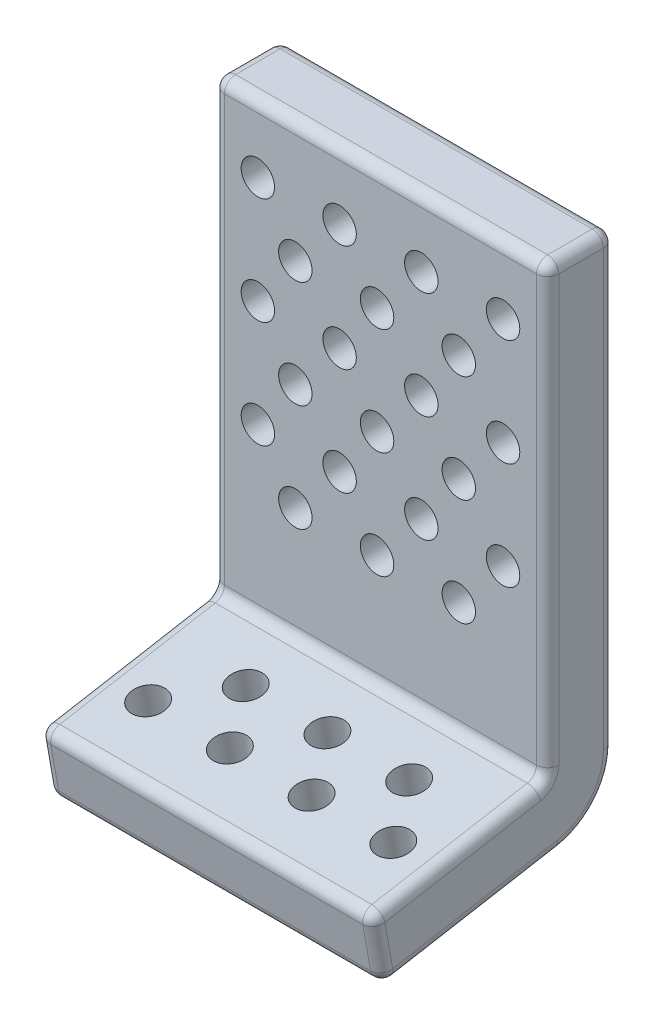
from build123d import *

# Parameters (mm, degrees)
EXTRUDE_1_DEPTH                = 15
SKETCH_2_R                     = 0.75
CUT_EXTRUDE_1_DEPTH            = 15
SKETCH_3_R                     = 0.75
CUT_EXTRUDE_2_DEPTH            = 15
CUT_EXTRUDE_START              = -2.7
SKETCH_2_2_R                   = 0.75
CUT_EXTRUDE_3_DEPTH            = 1
CUT_EXTRUDE_3_DRAFT            = 60
CUT_EXTRUDE_3_PROFILE_2_DEPTH  = 1
CUT_EXTRUDE_3_PROFILE_2_DRAFT  = 60
CUT_EXTRUDE_3_PROFILE_3_DEPTH  = 1
CUT_EXTRUDE_3_PROFILE_3_DRAFT  = 60
CUT_EXTRUDE_3_PROFILE_4_DEPTH  = 1
CUT_EXTRUDE_3_PROFILE_4_DRAFT  = 60
CUT_EXTRUDE_3_PROFILE_5_DEPTH  = 1
CUT_EXTRUDE_3_PROFILE_5_DRAFT  = 60
CUT_EXTRUDE_3_PROFILE_6_DEPTH  = 1
CUT_EXTRUDE_3_PROFILE_6_DRAFT  = 60
CUT_EXTRUDE_3_PROFILE_7_DEPTH  = 1
CUT_EXTRUDE_3_PROFILE_7_DRAFT  = 60
CUT_EXTRUDE_3_PROFILE_8_DEPTH  = 1
CUT_EXTRUDE_3_PROFILE_8_DRAFT  = 60
CUT_EXTRUDE_3_PROFILE_9_DEPTH  = 1
CUT_EXTRUDE_3_PROFILE_9_DRAFT  = 60
CUT_EXTRUDE_3_PROFILE_10_DEPTH = 1
CUT_EXTRUDE_3_PROFILE_10_DRAFT = 60
CUT_EXTRUDE_3_PROFILE_11_DEPTH = 1
CUT_EXTRUDE_3_PROFILE_11_DRAFT = 60
CUT_EXTRUDE_3_PROFILE_12_DEPTH = 1
CUT_EXTRUDE_3_PROFILE_12_DRAFT = 60
CUT_EXTRUDE_3_PROFILE_13_DEPTH = 1
CUT_EXTRUDE_3_PROFILE_13_DRAFT = 60
CUT_EXTRUDE_3_PROFILE_14_DEPTH = 1
CUT_EXTRUDE_3_PROFILE_14_DRAFT = 60
CUT_EXTRUDE_3_PROFILE_15_DEPTH = 1
CUT_EXTRUDE_3_PROFILE_15_DRAFT = 60
CUT_EXTRUDE_3_PROFILE_16_DEPTH = 1
CUT_EXTRUDE_3_PROFILE_16_DRAFT = 60
CUT_EXTRUDE_3_PROFILE_17_DEPTH = 1
CUT_EXTRUDE_3_PROFILE_17_DRAFT = 60
CUT_EXTRUDE_3_PROFILE_18_DEPTH = 1
CUT_EXTRUDE_3_PROFILE_18_DRAFT = 60
CUT_EXTRUDE_3_PROFILE_19_DEPTH = 1
CUT_EXTRUDE_3_PROFILE_19_DRAFT = 60
CUT_EXTRUDE_3_PROFILE_20_DEPTH = 1
CUT_EXTRUDE_3_PROFILE_20_DRAFT = 60
CUT_EXTRUDE_3_PROFILE_21_DEPTH = 1
CUT_EXTRUDE_3_PROFILE_21_DRAFT = 60
CUT_EXTRUDE_START_2            = 2.7
SKETCH_3_2_R                   = 0.75
CUT_EXTRUDE_4_DEPTH            = 1
CUT_EXTRUDE_4_DRAFT            = -60
CUT_EXTRUDE_4_PROFILE_2_DEPTH  = 1
CUT_EXTRUDE_4_PROFILE_2_DRAFT  = -60
CUT_EXTRUDE_4_PROFILE_3_DEPTH  = 1
CUT_EXTRUDE_4_PROFILE_3_DRAFT  = -60
CUT_EXTRUDE_4_PROFILE_4_DEPTH  = 1
CUT_EXTRUDE_4_PROFILE_4_DRAFT  = -60
CUT_EXTRUDE_4_PROFILE_5_DEPTH  = 1
CUT_EXTRUDE_4_PROFILE_5_DRAFT  = -60
CUT_EXTRUDE_4_PROFILE_6_DEPTH  = 1
CUT_EXTRUDE_4_PROFILE_6_DRAFT  = -60
CUT_EXTRUDE_4_PROFILE_7_DEPTH  = 1
CUT_EXTRUDE_4_PROFILE_7_DRAFT  = -60
FILLET_1_R                     = 0.5


with BuildPart() as part:
    # Эскиз1 → Бобышка-Вытянуть1 (new body)
    with BuildSketch(Plane(origin=(0, 0, 0), x_dir=(0, 0, -1), z_dir=(1, 0, 0))):
        with BuildLine():
            Line((0, 0), (-3, 0))
            Line((-3, 0), (-3, -20))
            Line((-3, -20), (-10.878462024, -21.389185421))
            Line((-10.878462024, -21.389185421), (-10.357517491, -24.34360868))
            Line((-10.357517491, -24.34360868), (-2.479055467, -22.954423259))
            ThreePointArc((-2.479055467, -22.954423259), (-0.701866671, -21.928362829), (0, -20))
            Line((0, -20), (0, 0))
        make_face()
    extrude(amount=EXTRUDE_1_DEPTH)

    # Эскиз2 → Вырез-Вытянуть1 (cut)
    with BuildSketch(Plane.XY.offset(3)):
        with Locations((2, -3)):
            Circle(SKETCH_2_R)
        with Locations((5.666666667, -3)):
            Circle(SKETCH_2_R)
        with Locations((9.333333333, -3)):
            Circle(SKETCH_2_R)
        with Locations((13, -3)):
            Circle(SKETCH_2_R)
        with Locations((3.680498092, -5.4)):
            Circle(SKETCH_2_R)
        with Locations((7.347164758, -5.4)):
            Circle(SKETCH_2_R)
        with Locations((11.013831425, -5.4)):
            Circle(SKETCH_2_R)
        with Locations((2, -7.8)):
            Circle(SKETCH_2_R)
        with Locations((5.666666667, -7.8)):
            Circle(SKETCH_2_R)
        with Locations((3.680498092, -10.2)):
            Circle(SKETCH_2_R)
        with Locations((7.347164758, -10.2)):
            Circle(SKETCH_2_R)
        with Locations((9.333333333, -7.8)):
            Circle(SKETCH_2_R)
        with Locations((11.013831425, -10.2)):
            Circle(SKETCH_2_R)
        with Locations((13, -7.8)):
            Circle(SKETCH_2_R)
        with Locations((2, -12.6)):
            Circle(SKETCH_2_R)
        with Locations((5.666666667, -12.6)):
            Circle(SKETCH_2_R)
        with Locations((3.680498092, -15)):
            Circle(SKETCH_2_R)
        with Locations((7.347164758, -15)):
            Circle(SKETCH_2_R)
        with Locations((9.333333333, -12.6)):
            Circle(SKETCH_2_R)
        with Locations((11.013831425, -15)):
            Circle(SKETCH_2_R)
        with Locations((13, -12.6)):
            Circle(SKETCH_2_R)
    extrude(amount=-CUT_EXTRUDE_1_DEPTH, mode=Mode.SUBTRACT)

    # Эскиз3 → Вырез-Вытянуть2 (cut)
    with BuildSketch(Plane(origin=(0, -23.26814693, 21.534582269), x_dir=(1, 0, 0), z_dir=(0, -0.9848077530122086, -0.1736481776669274))):
        with Locations((2, -13.820508076)):
            Circle(SKETCH_3_R)
        with Locations((5.666666667, -13.820508076)):
            Circle(SKETCH_3_R)
        with Locations((9.333333333, -13.820508076)):
            Circle(SKETCH_3_R)
        with Locations((13, -13.820508076)):
            Circle(SKETCH_3_R)
        with Locations((4.013839115, -16.220508076)):
            Circle(SKETCH_3_R)
        with Locations((7.680505781, -16.220508076)):
            Circle(SKETCH_3_R)
        with Locations((11.347172448, -16.220508076)):
            Circle(SKETCH_3_R)
    extrude(amount=CUT_EXTRUDE_2_DEPTH, mode=Mode.SUBTRACT)


with BuildPart() as cut_extrude_3_tool:
    # Эскиз2<2> → Вырез-Вытянуть3 (with draft: the straight prism first)
    with BuildSketch(Plane.XY.offset(3).offset(CUT_EXTRUDE_START)):
        with Locations((2, -3)):
            Circle(SKETCH_2_2_R)
    extrude(amount=-CUT_EXTRUDE_3_DEPTH)
    # Вырез-Вытянуть3: the draft: its side faces are tilted about the plane it starts from
    cut_extrude_3_sides = [cut_extrude_3_tool.faces().sort_by_distance(p)[0] for p in [
        (1.25, -3, -0.2),
    ]]
    draft(cut_extrude_3_sides, Plane.XY.offset(3).offset(CUT_EXTRUDE_START), CUT_EXTRUDE_3_DRAFT)


with BuildPart() as part_1:
    add(part.part)

    # Вырез-Вытянуть3: cut by cut_extrude_3_tool
    add(cut_extrude_3_tool.part, mode=Mode.SUBTRACT)


with BuildPart() as cut_extrude_3_profile_2_tool:
    # Эскиз2<2> → Вырез-Вытянуть3 profile 2 (with draft: the straight prism first)
    with BuildSketch(Plane.XY.offset(3).offset(CUT_EXTRUDE_START)):
        with Locations((5.666666667, -3)):
            Circle(SKETCH_2_2_R)
    extrude(amount=-CUT_EXTRUDE_3_PROFILE_2_DEPTH)
    # Вырез-Вытянуть3 profile 2: the draft: its side faces are tilted about the plane it starts from
    cut_extrude_3_profile_2_sides = [cut_extrude_3_profile_2_tool.faces().sort_by_distance(p)[0] for p in [
        (4.916666667, -3, -0.2),
    ]]
    draft(cut_extrude_3_profile_2_sides, Plane.XY.offset(3).offset(CUT_EXTRUDE_START), CUT_EXTRUDE_3_PROFILE_2_DRAFT)


with BuildPart() as part_2:
    add(part_1.part)

    # Вырез-Вытянуть3 profile 2: cut by cut_extrude_3_profile_2_tool
    add(cut_extrude_3_profile_2_tool.part, mode=Mode.SUBTRACT)


with BuildPart() as cut_extrude_3_profile_3_tool:
    # Эскиз2<2> → Вырез-Вытянуть3 profile 3 (with draft: the straight prism first)
    with BuildSketch(Plane.XY.offset(3).offset(CUT_EXTRUDE_START)):
        with Locations((9.333333333, -3)):
            Circle(SKETCH_2_2_R)
    extrude(amount=-CUT_EXTRUDE_3_PROFILE_3_DEPTH)
    # Вырез-Вытянуть3 profile 3: the draft: its side faces are tilted about the plane it starts from
    cut_extrude_3_profile_3_sides = [cut_extrude_3_profile_3_tool.faces().sort_by_distance(p)[0] for p in [
        (8.583333333, -3, -0.2),
    ]]
    draft(cut_extrude_3_profile_3_sides, Plane.XY.offset(3).offset(CUT_EXTRUDE_START), CUT_EXTRUDE_3_PROFILE_3_DRAFT)


with BuildPart() as part_3:
    add(part_2.part)

    # Вырез-Вытянуть3 profile 3: cut by cut_extrude_3_profile_3_tool
    add(cut_extrude_3_profile_3_tool.part, mode=Mode.SUBTRACT)


with BuildPart() as cut_extrude_3_profile_4_tool:
    # Эскиз2<2> → Вырез-Вытянуть3 profile 4 (with draft: the straight prism first)
    with BuildSketch(Plane.XY.offset(3).offset(CUT_EXTRUDE_START)):
        with Locations((13, -3)):
            Circle(SKETCH_2_2_R)
    extrude(amount=-CUT_EXTRUDE_3_PROFILE_4_DEPTH)
    # Вырез-Вытянуть3 profile 4: the draft: its side faces are tilted about the plane it starts from
    cut_extrude_3_profile_4_sides = [cut_extrude_3_profile_4_tool.faces().sort_by_distance(p)[0] for p in [
        (12.25, -3, -0.2),
    ]]
    draft(cut_extrude_3_profile_4_sides, Plane.XY.offset(3).offset(CUT_EXTRUDE_START), CUT_EXTRUDE_3_PROFILE_4_DRAFT)


with BuildPart() as part_4:
    add(part_3.part)

    # Вырез-Вытянуть3 profile 4: cut by cut_extrude_3_profile_4_tool
    add(cut_extrude_3_profile_4_tool.part, mode=Mode.SUBTRACT)


with BuildPart() as cut_extrude_3_profile_5_tool:
    # Эскиз2<2> → Вырез-Вытянуть3 profile 5 (with draft: the straight prism first)
    with BuildSketch(Plane.XY.offset(3).offset(CUT_EXTRUDE_START)):
        with Locations((3.680498092, -5.4)):
            Circle(SKETCH_2_2_R)
    extrude(amount=-CUT_EXTRUDE_3_PROFILE_5_DEPTH)
    # Вырез-Вытянуть3 profile 5: the draft: its side faces are tilted about the plane it starts from
    cut_extrude_3_profile_5_sides = [cut_extrude_3_profile_5_tool.faces().sort_by_distance(p)[0] for p in [
        (2.930498092, -5.4, -0.2),
    ]]
    draft(cut_extrude_3_profile_5_sides, Plane.XY.offset(3).offset(CUT_EXTRUDE_START), CUT_EXTRUDE_3_PROFILE_5_DRAFT)


with BuildPart() as part_5:
    add(part_4.part)

    # Вырез-Вытянуть3 profile 5: cut by cut_extrude_3_profile_5_tool
    add(cut_extrude_3_profile_5_tool.part, mode=Mode.SUBTRACT)


with BuildPart() as cut_extrude_3_profile_6_tool:
    # Эскиз2<2> → Вырез-Вытянуть3 profile 6 (with draft: the straight prism first)
    with BuildSketch(Plane.XY.offset(3).offset(CUT_EXTRUDE_START)):
        with Locations((7.347164758, -5.4)):
            Circle(SKETCH_2_2_R)
    extrude(amount=-CUT_EXTRUDE_3_PROFILE_6_DEPTH)
    # Вырез-Вытянуть3 profile 6: the draft: its side faces are tilted about the plane it starts from
    cut_extrude_3_profile_6_sides = [cut_extrude_3_profile_6_tool.faces().sort_by_distance(p)[0] for p in [
        (6.597164758, -5.4, -0.2),
    ]]
    draft(cut_extrude_3_profile_6_sides, Plane.XY.offset(3).offset(CUT_EXTRUDE_START), CUT_EXTRUDE_3_PROFILE_6_DRAFT)


with BuildPart() as part_6:
    add(part_5.part)

    # Вырез-Вытянуть3 profile 6: cut by cut_extrude_3_profile_6_tool
    add(cut_extrude_3_profile_6_tool.part, mode=Mode.SUBTRACT)


with BuildPart() as cut_extrude_3_profile_7_tool:
    # Эскиз2<2> → Вырез-Вытянуть3 profile 7 (with draft: the straight prism first)
    with BuildSketch(Plane.XY.offset(3).offset(CUT_EXTRUDE_START)):
        with Locations((11.013831425, -5.4)):
            Circle(SKETCH_2_2_R)
    extrude(amount=-CUT_EXTRUDE_3_PROFILE_7_DEPTH)
    # Вырез-Вытянуть3 profile 7: the draft: its side faces are tilted about the plane it starts from
    cut_extrude_3_profile_7_sides = [cut_extrude_3_profile_7_tool.faces().sort_by_distance(p)[0] for p in [
        (10.263831425, -5.4, -0.2),
    ]]
    draft(cut_extrude_3_profile_7_sides, Plane.XY.offset(3).offset(CUT_EXTRUDE_START), CUT_EXTRUDE_3_PROFILE_7_DRAFT)


with BuildPart() as part_7:
    add(part_6.part)

    # Вырез-Вытянуть3 profile 7: cut by cut_extrude_3_profile_7_tool
    add(cut_extrude_3_profile_7_tool.part, mode=Mode.SUBTRACT)


with BuildPart() as cut_extrude_3_profile_8_tool:
    # Эскиз2<2> → Вырез-Вытянуть3 profile 8 (with draft: the straight prism first)
    with BuildSketch(Plane.XY.offset(3).offset(CUT_EXTRUDE_START)):
        with Locations((2, -7.8)):
            Circle(SKETCH_2_2_R)
    extrude(amount=-CUT_EXTRUDE_3_PROFILE_8_DEPTH)
    # Вырез-Вытянуть3 profile 8: the draft: its side faces are tilted about the plane it starts from
    cut_extrude_3_profile_8_sides = [cut_extrude_3_profile_8_tool.faces().sort_by_distance(p)[0] for p in [
        (1.25, -7.8, -0.2),
    ]]
    draft(cut_extrude_3_profile_8_sides, Plane.XY.offset(3).offset(CUT_EXTRUDE_START), CUT_EXTRUDE_3_PROFILE_8_DRAFT)


with BuildPart() as part_8:
    add(part_7.part)

    # Вырез-Вытянуть3 profile 8: cut by cut_extrude_3_profile_8_tool
    add(cut_extrude_3_profile_8_tool.part, mode=Mode.SUBTRACT)


with BuildPart() as cut_extrude_3_profile_9_tool:
    # Эскиз2<2> → Вырез-Вытянуть3 profile 9 (with draft: the straight prism first)
    with BuildSketch(Plane.XY.offset(3).offset(CUT_EXTRUDE_START)):
        with Locations((5.666666667, -7.8)):
            Circle(SKETCH_2_2_R)
    extrude(amount=-CUT_EXTRUDE_3_PROFILE_9_DEPTH)
    # Вырез-Вытянуть3 profile 9: the draft: its side faces are tilted about the plane it starts from
    cut_extrude_3_profile_9_sides = [cut_extrude_3_profile_9_tool.faces().sort_by_distance(p)[0] for p in [
        (4.916666667, -7.8, -0.2),
    ]]
    draft(cut_extrude_3_profile_9_sides, Plane.XY.offset(3).offset(CUT_EXTRUDE_START), CUT_EXTRUDE_3_PROFILE_9_DRAFT)


with BuildPart() as part_9:
    add(part_8.part)

    # Вырез-Вытянуть3 profile 9: cut by cut_extrude_3_profile_9_tool
    add(cut_extrude_3_profile_9_tool.part, mode=Mode.SUBTRACT)


with BuildPart() as cut_extrude_3_profile_10_tool:
    # Эскиз2<2> → Вырез-Вытянуть3 profile 10 (with draft: the straight prism first)
    with BuildSketch(Plane.XY.offset(3).offset(CUT_EXTRUDE_START)):
        with Locations((3.680498092, -10.2)):
            Circle(SKETCH_2_2_R)
    extrude(amount=-CUT_EXTRUDE_3_PROFILE_10_DEPTH)
    # Вырез-Вытянуть3 profile 10: the draft: its side faces are tilted about the plane it starts from
    cut_extrude_3_profile_10_sides = [cut_extrude_3_profile_10_tool.faces().sort_by_distance(p)[0] for p in [
        (2.930498092, -10.2, -0.2),
    ]]
    draft(cut_extrude_3_profile_10_sides, Plane.XY.offset(3).offset(CUT_EXTRUDE_START), CUT_EXTRUDE_3_PROFILE_10_DRAFT)


with BuildPart() as part_10:
    add(part_9.part)

    # Вырез-Вытянуть3 profile 10: cut by cut_extrude_3_profile_10_tool
    add(cut_extrude_3_profile_10_tool.part, mode=Mode.SUBTRACT)


with BuildPart() as cut_extrude_3_profile_11_tool:
    # Эскиз2<2> → Вырез-Вытянуть3 profile 11 (with draft: the straight prism first)
    with BuildSketch(Plane.XY.offset(3).offset(CUT_EXTRUDE_START)):
        with Locations((7.347164758, -10.2)):
            Circle(SKETCH_2_2_R)
    extrude(amount=-CUT_EXTRUDE_3_PROFILE_11_DEPTH)
    # Вырез-Вытянуть3 profile 11: the draft: its side faces are tilted about the plane it starts from
    cut_extrude_3_profile_11_sides = [cut_extrude_3_profile_11_tool.faces().sort_by_distance(p)[0] for p in [
        (6.597164758, -10.2, -0.2),
    ]]
    draft(cut_extrude_3_profile_11_sides, Plane.XY.offset(3).offset(CUT_EXTRUDE_START), CUT_EXTRUDE_3_PROFILE_11_DRAFT)


with BuildPart() as part_11:
    add(part_10.part)

    # Вырез-Вытянуть3 profile 11: cut by cut_extrude_3_profile_11_tool
    add(cut_extrude_3_profile_11_tool.part, mode=Mode.SUBTRACT)


with BuildPart() as cut_extrude_3_profile_12_tool:
    # Эскиз2<2> → Вырез-Вытянуть3 profile 12 (with draft: the straight prism first)
    with BuildSketch(Plane.XY.offset(3).offset(CUT_EXTRUDE_START)):
        with Locations((9.333333333, -7.8)):
            Circle(SKETCH_2_2_R)
    extrude(amount=-CUT_EXTRUDE_3_PROFILE_12_DEPTH)
    # Вырез-Вытянуть3 profile 12: the draft: its side faces are tilted about the plane it starts from
    cut_extrude_3_profile_12_sides = [cut_extrude_3_profile_12_tool.faces().sort_by_distance(p)[0] for p in [
        (8.583333333, -7.8, -0.2),
    ]]
    draft(cut_extrude_3_profile_12_sides, Plane.XY.offset(3).offset(CUT_EXTRUDE_START), CUT_EXTRUDE_3_PROFILE_12_DRAFT)


with BuildPart() as part_12:
    add(part_11.part)

    # Вырез-Вытянуть3 profile 12: cut by cut_extrude_3_profile_12_tool
    add(cut_extrude_3_profile_12_tool.part, mode=Mode.SUBTRACT)


with BuildPart() as cut_extrude_3_profile_13_tool:
    # Эскиз2<2> → Вырез-Вытянуть3 profile 13 (with draft: the straight prism first)
    with BuildSketch(Plane.XY.offset(3).offset(CUT_EXTRUDE_START)):
        with Locations((11.013831425, -10.2)):
            Circle(SKETCH_2_2_R)
    extrude(amount=-CUT_EXTRUDE_3_PROFILE_13_DEPTH)
    # Вырез-Вытянуть3 profile 13: the draft: its side faces are tilted about the plane it starts from
    cut_extrude_3_profile_13_sides = [cut_extrude_3_profile_13_tool.faces().sort_by_distance(p)[0] for p in [
        (10.263831425, -10.2, -0.2),
    ]]
    draft(cut_extrude_3_profile_13_sides, Plane.XY.offset(3).offset(CUT_EXTRUDE_START), CUT_EXTRUDE_3_PROFILE_13_DRAFT)


with BuildPart() as part_13:
    add(part_12.part)

    # Вырез-Вытянуть3 profile 13: cut by cut_extrude_3_profile_13_tool
    add(cut_extrude_3_profile_13_tool.part, mode=Mode.SUBTRACT)


with BuildPart() as cut_extrude_3_profile_14_tool:
    # Эскиз2<2> → Вырез-Вытянуть3 profile 14 (with draft: the straight prism first)
    with BuildSketch(Plane.XY.offset(3).offset(CUT_EXTRUDE_START)):
        with Locations((13, -7.8)):
            Circle(SKETCH_2_2_R)
    extrude(amount=-CUT_EXTRUDE_3_PROFILE_14_DEPTH)
    # Вырез-Вытянуть3 profile 14: the draft: its side faces are tilted about the plane it starts from
    cut_extrude_3_profile_14_sides = [cut_extrude_3_profile_14_tool.faces().sort_by_distance(p)[0] for p in [
        (12.25, -7.8, -0.2),
    ]]
    draft(cut_extrude_3_profile_14_sides, Plane.XY.offset(3).offset(CUT_EXTRUDE_START), CUT_EXTRUDE_3_PROFILE_14_DRAFT)


with BuildPart() as part_14:
    add(part_13.part)

    # Вырез-Вытянуть3 profile 14: cut by cut_extrude_3_profile_14_tool
    add(cut_extrude_3_profile_14_tool.part, mode=Mode.SUBTRACT)


with BuildPart() as cut_extrude_3_profile_15_tool:
    # Эскиз2<2> → Вырез-Вытянуть3 profile 15 (with draft: the straight prism first)
    with BuildSketch(Plane.XY.offset(3).offset(CUT_EXTRUDE_START)):
        with Locations((2, -12.6)):
            Circle(SKETCH_2_2_R)
    extrude(amount=-CUT_EXTRUDE_3_PROFILE_15_DEPTH)
    # Вырез-Вытянуть3 profile 15: the draft: its side faces are tilted about the plane it starts from
    cut_extrude_3_profile_15_sides = [cut_extrude_3_profile_15_tool.faces().sort_by_distance(p)[0] for p in [
        (1.25, -12.6, -0.2),
    ]]
    draft(cut_extrude_3_profile_15_sides, Plane.XY.offset(3).offset(CUT_EXTRUDE_START), CUT_EXTRUDE_3_PROFILE_15_DRAFT)


with BuildPart() as part_15:
    add(part_14.part)

    # Вырез-Вытянуть3 profile 15: cut by cut_extrude_3_profile_15_tool
    add(cut_extrude_3_profile_15_tool.part, mode=Mode.SUBTRACT)


with BuildPart() as cut_extrude_3_profile_16_tool:
    # Эскиз2<2> → Вырез-Вытянуть3 profile 16 (with draft: the straight prism first)
    with BuildSketch(Plane.XY.offset(3).offset(CUT_EXTRUDE_START)):
        with Locations((5.666666667, -12.6)):
            Circle(SKETCH_2_2_R)
    extrude(amount=-CUT_EXTRUDE_3_PROFILE_16_DEPTH)
    # Вырез-Вытянуть3 profile 16: the draft: its side faces are tilted about the plane it starts from
    cut_extrude_3_profile_16_sides = [cut_extrude_3_profile_16_tool.faces().sort_by_distance(p)[0] for p in [
        (4.916666667, -12.6, -0.2),
    ]]
    draft(cut_extrude_3_profile_16_sides, Plane.XY.offset(3).offset(CUT_EXTRUDE_START), CUT_EXTRUDE_3_PROFILE_16_DRAFT)


with BuildPart() as part_16:
    add(part_15.part)

    # Вырез-Вытянуть3 profile 16: cut by cut_extrude_3_profile_16_tool
    add(cut_extrude_3_profile_16_tool.part, mode=Mode.SUBTRACT)


with BuildPart() as cut_extrude_3_profile_17_tool:
    # Эскиз2<2> → Вырез-Вытянуть3 profile 17 (with draft: the straight prism first)
    with BuildSketch(Plane.XY.offset(3).offset(CUT_EXTRUDE_START)):
        with Locations((3.680498092, -15)):
            Circle(SKETCH_2_2_R)
    extrude(amount=-CUT_EXTRUDE_3_PROFILE_17_DEPTH)
    # Вырез-Вытянуть3 profile 17: the draft: its side faces are tilted about the plane it starts from
    cut_extrude_3_profile_17_sides = [cut_extrude_3_profile_17_tool.faces().sort_by_distance(p)[0] for p in [
        (2.930498092, -15, -0.2),
    ]]
    draft(cut_extrude_3_profile_17_sides, Plane.XY.offset(3).offset(CUT_EXTRUDE_START), CUT_EXTRUDE_3_PROFILE_17_DRAFT)


with BuildPart() as part_17:
    add(part_16.part)

    # Вырез-Вытянуть3 profile 17: cut by cut_extrude_3_profile_17_tool
    add(cut_extrude_3_profile_17_tool.part, mode=Mode.SUBTRACT)


with BuildPart() as cut_extrude_3_profile_18_tool:
    # Эскиз2<2> → Вырез-Вытянуть3 profile 18 (with draft: the straight prism first)
    with BuildSketch(Plane.XY.offset(3).offset(CUT_EXTRUDE_START)):
        with Locations((7.347164758, -15)):
            Circle(SKETCH_2_2_R)
    extrude(amount=-CUT_EXTRUDE_3_PROFILE_18_DEPTH)
    # Вырез-Вытянуть3 profile 18: the draft: its side faces are tilted about the plane it starts from
    cut_extrude_3_profile_18_sides = [cut_extrude_3_profile_18_tool.faces().sort_by_distance(p)[0] for p in [
        (6.597164758, -15, -0.2),
    ]]
    draft(cut_extrude_3_profile_18_sides, Plane.XY.offset(3).offset(CUT_EXTRUDE_START), CUT_EXTRUDE_3_PROFILE_18_DRAFT)


with BuildPart() as part_18:
    add(part_17.part)

    # Вырез-Вытянуть3 profile 18: cut by cut_extrude_3_profile_18_tool
    add(cut_extrude_3_profile_18_tool.part, mode=Mode.SUBTRACT)


with BuildPart() as cut_extrude_3_profile_19_tool:
    # Эскиз2<2> → Вырез-Вытянуть3 profile 19 (with draft: the straight prism first)
    with BuildSketch(Plane.XY.offset(3).offset(CUT_EXTRUDE_START)):
        with Locations((9.333333333, -12.6)):
            Circle(SKETCH_2_2_R)
    extrude(amount=-CUT_EXTRUDE_3_PROFILE_19_DEPTH)
    # Вырез-Вытянуть3 profile 19: the draft: its side faces are tilted about the plane it starts from
    cut_extrude_3_profile_19_sides = [cut_extrude_3_profile_19_tool.faces().sort_by_distance(p)[0] for p in [
        (8.583333333, -12.6, -0.2),
    ]]
    draft(cut_extrude_3_profile_19_sides, Plane.XY.offset(3).offset(CUT_EXTRUDE_START), CUT_EXTRUDE_3_PROFILE_19_DRAFT)


with BuildPart() as part_19:
    add(part_18.part)

    # Вырез-Вытянуть3 profile 19: cut by cut_extrude_3_profile_19_tool
    add(cut_extrude_3_profile_19_tool.part, mode=Mode.SUBTRACT)


with BuildPart() as cut_extrude_3_profile_20_tool:
    # Эскиз2<2> → Вырез-Вытянуть3 profile 20 (with draft: the straight prism first)
    with BuildSketch(Plane.XY.offset(3).offset(CUT_EXTRUDE_START)):
        with Locations((11.013831425, -15)):
            Circle(SKETCH_2_2_R)
    extrude(amount=-CUT_EXTRUDE_3_PROFILE_20_DEPTH)
    # Вырез-Вытянуть3 profile 20: the draft: its side faces are tilted about the plane it starts from
    cut_extrude_3_profile_20_sides = [cut_extrude_3_profile_20_tool.faces().sort_by_distance(p)[0] for p in [
        (10.263831425, -15, -0.2),
    ]]
    draft(cut_extrude_3_profile_20_sides, Plane.XY.offset(3).offset(CUT_EXTRUDE_START), CUT_EXTRUDE_3_PROFILE_20_DRAFT)


with BuildPart() as part_20:
    add(part_19.part)

    # Вырез-Вытянуть3 profile 20: cut by cut_extrude_3_profile_20_tool
    add(cut_extrude_3_profile_20_tool.part, mode=Mode.SUBTRACT)


with BuildPart() as cut_extrude_3_profile_21_tool:
    # Эскиз2<2> → Вырез-Вытянуть3 profile 21 (with draft: the straight prism first)
    with BuildSketch(Plane.XY.offset(3).offset(CUT_EXTRUDE_START)):
        with Locations((13, -12.6)):
            Circle(SKETCH_2_2_R)
    extrude(amount=-CUT_EXTRUDE_3_PROFILE_21_DEPTH)
    # Вырез-Вытянуть3 profile 21: the draft: its side faces are tilted about the plane it starts from
    cut_extrude_3_profile_21_sides = [cut_extrude_3_profile_21_tool.faces().sort_by_distance(p)[0] for p in [
        (12.25, -12.6, -0.2),
    ]]
    draft(cut_extrude_3_profile_21_sides, Plane.XY.offset(3).offset(CUT_EXTRUDE_START), CUT_EXTRUDE_3_PROFILE_21_DRAFT)


with BuildPart() as part_21:
    add(part_20.part)

    # Вырез-Вытянуть3 profile 21: cut by cut_extrude_3_profile_21_tool
    add(cut_extrude_3_profile_21_tool.part, mode=Mode.SUBTRACT)


with BuildPart() as cut_extrude_4_tool:
    # Эскиз3<2> → Вырез-Вытянуть4 (with draft: the straight prism first)
    with BuildSketch(Plane(origin=(0, -23.26814693, 21.534582269), x_dir=(1, 0, 0), z_dir=(0, -0.9848077530122086, -0.1736481776669274)).offset(CUT_EXTRUDE_START_2)):
        with Locations((2, -13.820508076)):
            Circle(SKETCH_3_2_R)
    extrude(amount=CUT_EXTRUDE_4_DEPTH)
    # Вырез-Вытянуть4: the draft: its side faces are tilted about the plane it starts from
    cut_extrude_4_sides = [cut_extrude_4_tool.faces().sort_by_distance(p)[0] for p in [
        (1.25, -24.019625698, 7.368364597),
    ]]
    draft(cut_extrude_4_sides, Plane(origin=(0, -23.26814693, 21.534582269), x_dir=(1, 0, 0), z_dir=(0, -0.9848077530122086, -0.1736481776669274)).offset(CUT_EXTRUDE_START_2), CUT_EXTRUDE_4_DRAFT)


with BuildPart() as part_22:
    add(part_21.part)

    # Вырез-Вытянуть4: cut by cut_extrude_4_tool
    add(cut_extrude_4_tool.part, mode=Mode.SUBTRACT)


with BuildPart() as cut_extrude_4_profile_2_tool:
    # Эскиз3<2> → Вырез-Вытянуть4 profile 2 (with draft: the straight prism first)
    with BuildSketch(Plane(origin=(0, -23.26814693, 21.534582269), x_dir=(1, 0, 0), z_dir=(0, -0.9848077530122086, -0.1736481776669274)).offset(CUT_EXTRUDE_START_2)):
        with Locations((5.666666667, -13.820508076)):
            Circle(SKETCH_3_2_R)
    extrude(amount=CUT_EXTRUDE_4_PROFILE_2_DEPTH)
    # Вырез-Вытянуть4 profile 2: the draft: its side faces are tilted about the plane it starts from
    cut_extrude_4_profile_2_sides = [cut_extrude_4_profile_2_tool.faces().sort_by_distance(p)[0] for p in [
        (4.916666667, -24.019625698, 7.368364597),
    ]]
    draft(cut_extrude_4_profile_2_sides, Plane(origin=(0, -23.26814693, 21.534582269), x_dir=(1, 0, 0), z_dir=(0, -0.9848077530122086, -0.1736481776669274)).offset(CUT_EXTRUDE_START_2), CUT_EXTRUDE_4_PROFILE_2_DRAFT)


with BuildPart() as part_23:
    add(part_22.part)

    # Вырез-Вытянуть4 profile 2: cut by cut_extrude_4_profile_2_tool
    add(cut_extrude_4_profile_2_tool.part, mode=Mode.SUBTRACT)


with BuildPart() as cut_extrude_4_profile_3_tool:
    # Эскиз3<2> → Вырез-Вытянуть4 profile 3 (with draft: the straight prism first)
    with BuildSketch(Plane(origin=(0, -23.26814693, 21.534582269), x_dir=(1, 0, 0), z_dir=(0, -0.9848077530122086, -0.1736481776669274)).offset(CUT_EXTRUDE_START_2)):
        with Locations((9.333333333, -13.820508076)):
            Circle(SKETCH_3_2_R)
    extrude(amount=CUT_EXTRUDE_4_PROFILE_3_DEPTH)
    # Вырез-Вытянуть4 profile 3: the draft: its side faces are tilted about the plane it starts from
    cut_extrude_4_profile_3_sides = [cut_extrude_4_profile_3_tool.faces().sort_by_distance(p)[0] for p in [
        (8.583333333, -24.019625698, 7.368364597),
    ]]
    draft(cut_extrude_4_profile_3_sides, Plane(origin=(0, -23.26814693, 21.534582269), x_dir=(1, 0, 0), z_dir=(0, -0.9848077530122086, -0.1736481776669274)).offset(CUT_EXTRUDE_START_2), CUT_EXTRUDE_4_PROFILE_3_DRAFT)


with BuildPart() as part_24:
    add(part_23.part)

    # Вырез-Вытянуть4 profile 3: cut by cut_extrude_4_profile_3_tool
    add(cut_extrude_4_profile_3_tool.part, mode=Mode.SUBTRACT)


with BuildPart() as cut_extrude_4_profile_4_tool:
    # Эскиз3<2> → Вырез-Вытянуть4 profile 4 (with draft: the straight prism first)
    with BuildSketch(Plane(origin=(0, -23.26814693, 21.534582269), x_dir=(1, 0, 0), z_dir=(0, -0.9848077530122086, -0.1736481776669274)).offset(CUT_EXTRUDE_START_2)):
        with Locations((13, -13.820508076)):
            Circle(SKETCH_3_2_R)
    extrude(amount=CUT_EXTRUDE_4_PROFILE_4_DEPTH)
    # Вырез-Вытянуть4 profile 4: the draft: its side faces are tilted about the plane it starts from
    cut_extrude_4_profile_4_sides = [cut_extrude_4_profile_4_tool.faces().sort_by_distance(p)[0] for p in [
        (12.25, -24.019625698, 7.368364597),
    ]]
    draft(cut_extrude_4_profile_4_sides, Plane(origin=(0, -23.26814693, 21.534582269), x_dir=(1, 0, 0), z_dir=(0, -0.9848077530122086, -0.1736481776669274)).offset(CUT_EXTRUDE_START_2), CUT_EXTRUDE_4_PROFILE_4_DRAFT)


with BuildPart() as part_25:
    add(part_24.part)

    # Вырез-Вытянуть4 profile 4: cut by cut_extrude_4_profile_4_tool
    add(cut_extrude_4_profile_4_tool.part, mode=Mode.SUBTRACT)


with BuildPart() as cut_extrude_4_profile_5_tool:
    # Эскиз3<2> → Вырез-Вытянуть4 profile 5 (with draft: the straight prism first)
    with BuildSketch(Plane(origin=(0, -23.26814693, 21.534582269), x_dir=(1, 0, 0), z_dir=(0, -0.9848077530122086, -0.1736481776669274)).offset(CUT_EXTRUDE_START_2)):
        with Locations((4.013839115, -16.220508076)):
            Circle(SKETCH_3_2_R)
    extrude(amount=CUT_EXTRUDE_4_PROFILE_5_DEPTH)
    # Вырез-Вытянуть4 profile 5: the draft: its side faces are tilted about the plane it starts from
    cut_extrude_4_profile_5_sides = [cut_extrude_4_profile_5_tool.faces().sort_by_distance(p)[0] for p in [
        (3.263839115, -23.602870072, 5.004825989),
    ]]
    draft(cut_extrude_4_profile_5_sides, Plane(origin=(0, -23.26814693, 21.534582269), x_dir=(1, 0, 0), z_dir=(0, -0.9848077530122086, -0.1736481776669274)).offset(CUT_EXTRUDE_START_2), CUT_EXTRUDE_4_PROFILE_5_DRAFT)


with BuildPart() as part_26:
    add(part_25.part)

    # Вырез-Вытянуть4 profile 5: cut by cut_extrude_4_profile_5_tool
    add(cut_extrude_4_profile_5_tool.part, mode=Mode.SUBTRACT)


with BuildPart() as cut_extrude_4_profile_6_tool:
    # Эскиз3<2> → Вырез-Вытянуть4 profile 6 (with draft: the straight prism first)
    with BuildSketch(Plane(origin=(0, -23.26814693, 21.534582269), x_dir=(1, 0, 0), z_dir=(0, -0.9848077530122086, -0.1736481776669274)).offset(CUT_EXTRUDE_START_2)):
        with Locations((7.680505781, -16.220508076)):
            Circle(SKETCH_3_2_R)
    extrude(amount=CUT_EXTRUDE_4_PROFILE_6_DEPTH)
    # Вырез-Вытянуть4 profile 6: the draft: its side faces are tilted about the plane it starts from
    cut_extrude_4_profile_6_sides = [cut_extrude_4_profile_6_tool.faces().sort_by_distance(p)[0] for p in [
        (6.930505781, -23.602870072, 5.004825989),
    ]]
    draft(cut_extrude_4_profile_6_sides, Plane(origin=(0, -23.26814693, 21.534582269), x_dir=(1, 0, 0), z_dir=(0, -0.9848077530122086, -0.1736481776669274)).offset(CUT_EXTRUDE_START_2), CUT_EXTRUDE_4_PROFILE_6_DRAFT)


with BuildPart() as part_27:
    add(part_26.part)

    # Вырез-Вытянуть4 profile 6: cut by cut_extrude_4_profile_6_tool
    add(cut_extrude_4_profile_6_tool.part, mode=Mode.SUBTRACT)


with BuildPart() as cut_extrude_4_profile_7_tool:
    # Эскиз3<2> → Вырез-Вытянуть4 profile 7 (with draft: the straight prism first)
    with BuildSketch(Plane(origin=(0, -23.26814693, 21.534582269), x_dir=(1, 0, 0), z_dir=(0, -0.9848077530122086, -0.1736481776669274)).offset(CUT_EXTRUDE_START_2)):
        with Locations((11.347172448, -16.220508076)):
            Circle(SKETCH_3_2_R)
    extrude(amount=CUT_EXTRUDE_4_PROFILE_7_DEPTH)
    # Вырез-Вытянуть4 profile 7: the draft: its side faces are tilted about the plane it starts from
    cut_extrude_4_profile_7_sides = [cut_extrude_4_profile_7_tool.faces().sort_by_distance(p)[0] for p in [
        (10.597172448, -23.602870072, 5.004825989),
    ]]
    draft(cut_extrude_4_profile_7_sides, Plane(origin=(0, -23.26814693, 21.534582269), x_dir=(1, 0, 0), z_dir=(0, -0.9848077530122086, -0.1736481776669274)).offset(CUT_EXTRUDE_START_2), CUT_EXTRUDE_4_PROFILE_7_DRAFT)


with BuildPart() as part_28:
    add(part_27.part)

    # Вырез-Вытянуть4 profile 7: cut by cut_extrude_4_profile_7_tool
    add(cut_extrude_4_profile_7_tool.part, mode=Mode.SUBTRACT)

    # Скругление1
    fillet_1_edges = [part_28.edges().sort_by_distance(p)[0] for p in [
        (0, -10, 0),
        (15, -10, 0),
        (15, 0, 1.5),
        (7.5, 0, 0),
        (0, -10, 3),
        (7.5, 0, 3),
        (15, -10, 3),
        (0, -23.64901597, 6.418286479),
        (0, -21.928362829, 0.701866671),
        (15, -23.64901597, 6.418286479),
        (15, -21.928362829, 0.701866671),
        (0, 0, 1.5),
        (0, -22.866397051, 10.617989758),
        (15, -22.866397051, 10.617989758),
        (7.5, -24.34360868, 10.357517491),
        (7.5, -21.389185421, 10.878462024),
        (0, -20.694592711, 6.939231012),
        (15, -20.694592711, 6.939231012),
        (7.5, -20, 3),
    ]]
    fillet(fillet_1_edges, radius=FILLET_1_R)


solid = part_28.part
